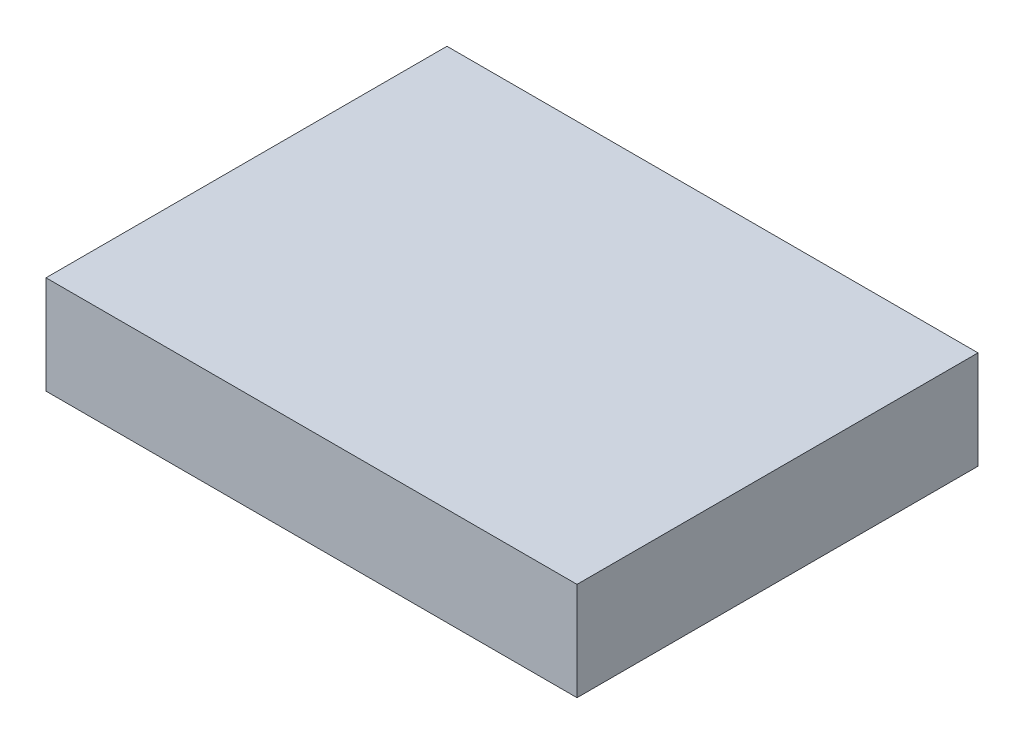
from build123d import *

# Parameters (mm, degrees)
SKETCH1_W           = 49
SKETCH1_H           = 37
BOSS_EXTRUDE1_DEPTH = 9.06


with BuildPart() as part:
    # Sketch1 → Boss-Extrude1 (new body)
    with BuildSketch(Plane(origin=(0, 0, 0), x_dir=(1, 0, 0), z_dir=(0, 1, 0))):
        with Locations((24.5, 18.5)):
            Rectangle(SKETCH1_W, SKETCH1_H)
    extrude(amount=BOSS_EXTRUDE1_DEPTH)


solid = part.part
